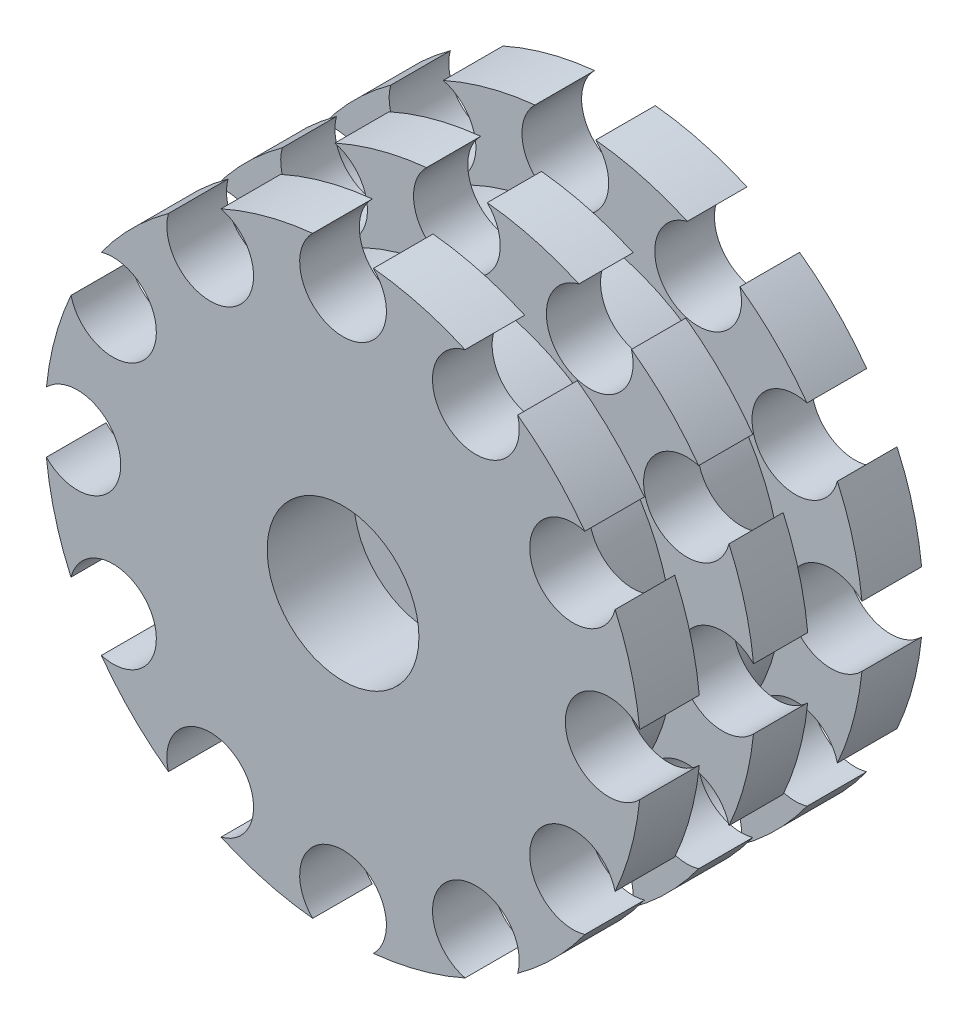
from build123d import *

# Parameters (mm, degrees)
CORTAR_EXTRUIR1_DEPTH   = 9
CROQUIS5_R              = 4
CORTAR_EXTRUIR3_DEPTH   = 27
CROQUIS6_R              = 2
CORTAR_EXTRUIR4_DEPTH   = 10
CROQUIS7_R              = 2
SALIENTE_EXTRUIR1_DEPTH = 4.5
CROQUIS8_R              = 7
CROQUIS8_R_2            = 2
CORTAR_EXTRUIR5_DEPTH   = 4.5


with BuildPart() as part:
    # Croquis1 → Revolución1 (revolve)
    with BuildSketch(Plane(origin=(0, 0, 0), x_dir=(1, 0, 0), z_dir=(0, 1, 0))):
        Polygon((0, 1.5), (0, -9.5), (7, -9.5), (7, -13), (12.5, -13), (27.5, -13), (27.5, -7.5), (20, -7.5), (20, -2.5), (27.5, -2.5), (27.5, 2.5), (20, 2.5), (20, 7.5), (27.5, 7.5), (27.5, 13), (12.5, 13), (12.5, 6.5), (7.5, 1.5), align=None)
    revolve(axis=Axis((0, 0, 0), (0, 0, -1)))

    # Croquis2 → Cortar-Extruir1 (cut)
    with BuildSketch(Plane(origin=(0, 0, -1.5), x_dir=(-1, 0, 0), z_dir=(0, 0, -1))):
        Polygon((7.505553499, 0), (3.75277675, 6.5), (-3.75277675, 6.5), (-7.505553499, 0), (-3.75277675, -6.5), (3.75277675, -6.5), align=None)
    extrude(amount=-CORTAR_EXTRUIR1_DEPTH, mode=Mode.SUBTRACT)

    # Croquis5 → Cortar-Extruir3 (cut, through all)
    with BuildSketch(Plane.XY.offset(13)):
        with Locations((0, 24.5)):
            Circle(CROQUIS5_R)
        with Locations((12.25, 21.217622393)):
            Circle(CROQUIS5_R)
        with Locations((21.217622393, 12.25)):
            Circle(CROQUIS5_R)
        with Locations((24.5, 0)):
            Circle(CROQUIS5_R)
        with Locations((21.217622393, -12.25)):
            Circle(CROQUIS5_R)
        with Locations((12.25, -21.217622393)):
            Circle(CROQUIS5_R)
        with Locations((0, -24.5)):
            Circle(CROQUIS5_R)
        with Locations((-12.25, -21.217622393)):
            Circle(CROQUIS5_R)
        with Locations((-21.217622393, -12.25)):
            Circle(CROQUIS5_R)
        with Locations((-24.5, 0)):
            Circle(CROQUIS5_R)
        with Locations((-21.217622393, 12.25)):
            Circle(CROQUIS5_R)
        with Locations((-12.25, 21.217622393)):
            Circle(CROQUIS5_R)
    extrude(amount=-CORTAR_EXTRUIR3_DEPTH, mode=Mode.SUBTRACT)

    # Croquis6 → Cortar-Extruir4 (cut)
    with BuildSketch(Plane(origin=(0, 0, 7.5), x_dir=(-1, 0, 0), z_dir=(0, 0, -1))):
        Circle(CROQUIS6_R)
    extrude(amount=-CORTAR_EXTRUIR4_DEPTH, mode=Mode.SUBTRACT)

    # Croquis7 → Saliente-Extruir1 (add)
    with BuildSketch(Plane(origin=(0, 0, 7.5), x_dir=(-1, 0, 0), z_dir=(0, 0, -1))):
        Polygon((3.75277675, -6.5), (7.505553499, 0), (3.75277675, 6.5), (-3.75277675, 6.5), (-7.505553499, 0), (-3.75277675, -6.5), align=None)
        Circle(CROQUIS7_R, mode=Mode.SUBTRACT)
    extrude(amount=SALIENTE_EXTRUIR1_DEPTH)

    # Croquis8 → Cortar-Extruir5 (cut)
    with BuildSketch(Plane.XY.offset(9.5)):
        Circle(CROQUIS8_R)
        Circle(CROQUIS8_R_2, mode=Mode.SUBTRACT)
    extrude(amount=-CORTAR_EXTRUIR5_DEPTH, mode=Mode.SUBTRACT)


solid = part.part
